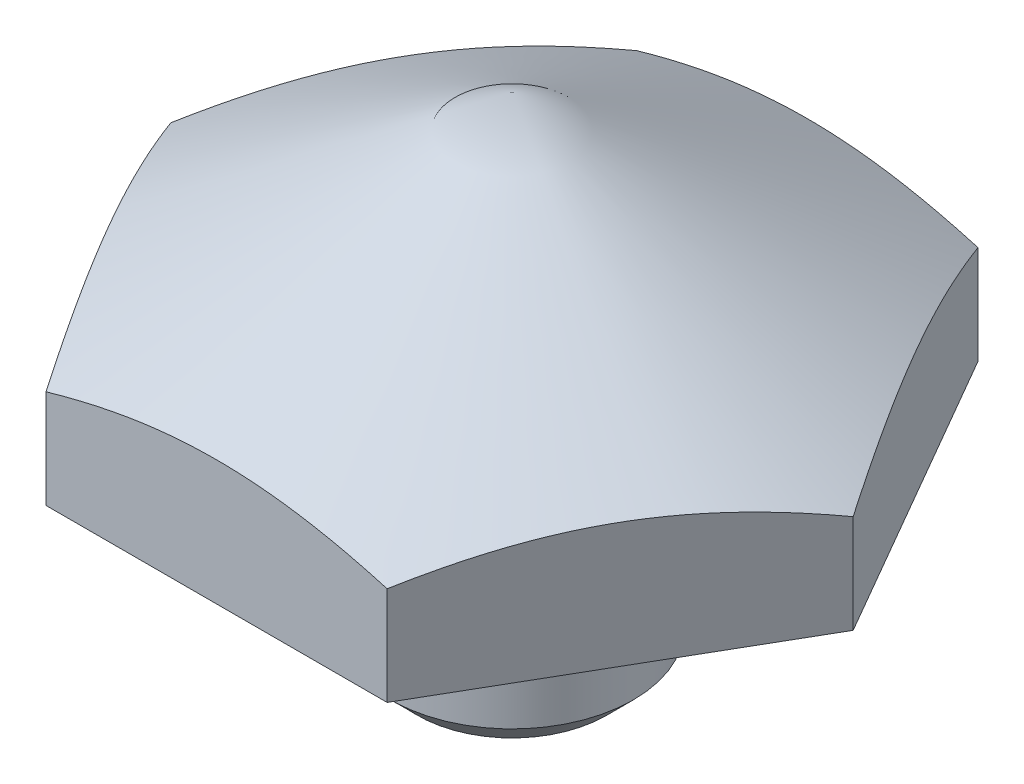
from build123d import *

# Parameters (mm, degrees)
CUT_EXTRUDE2_DEPTH = 15.875


with BuildPart() as part:
    # Sketch3 → Revolve1 (revolve)
    with BuildSketch(Plane.XY):
        with BuildLine():
            Line((0, 15.875), (10.9985175, 9.525002961))
            Line((10.9985175, 9.525002961), (10.9985175, 6.35))
            Line((10.9985175, 6.35), (3.429, 6.35))
            ThreePointArc((3.429, 6.35), (3.159592316, 6.238407684), (3.048, 5.969))
            Line((3.048, 5.969), (3.048, 4.3688))
            Line((3.048, 4.3688), (3.9116, 3.5052))
            Line((3.9116, 3.5052), (3.9116, 0.8636))
            Line((3.9116, 0.8636), (3.048, 0))
            Line((3.048, 0), (0, 0))
            Line((0, 0), (0, 15.875))
        make_face()
    revolve(axis=Axis((0, -1000, 0), (0, 1, 0)))

    # Sketch1 → Cut-Extrude2 (cut)
    with BuildSketch(Plane(origin=(0, 0, 0), x_dir=(1, 0, 0), z_dir=(0, 1, 0))):
        with BuildLine():
            ThreePointArc((-5.499261314, -9.525), (0, -10.998522628), (5.499261314, -9.525))
            Line((5.499261314, -9.525), (-5.499261314, -9.525))
        make_face()
        with BuildLine():
            ThreePointArc((-10.998522628, 0), (-9.525, -5.499261314), (-5.499261314, -9.525))
            Line((-5.499261314, -9.525), (-10.998522628, 0))
        make_face()
        with BuildLine():
            ThreePointArc((5.499261314, -9.525), (9.525, -5.499261314), (10.998522628, 0))
            Line((10.998522628, 0), (5.499261314, -9.525))
        make_face()
        with BuildLine():
            Line((5.499261314, 9.525), (10.998522628, 0))
            ThreePointArc((10.998522628, 0), (9.525, 5.499261314), (5.499261314, 9.525))
        make_face()
        with BuildLine():
            Line((-5.499261314, 9.525), (5.499261314, 9.525))
            ThreePointArc((5.499261314, 9.525), (0, 10.998522628), (-5.499261314, 9.525))
        make_face()
        with BuildLine():
            Line((-10.998522628, 0), (-5.499261314, 9.525))
            ThreePointArc((-5.499261314, 9.525), (-9.525, 5.499261314), (-10.998522628, 0))
        make_face()
    extrude(amount=CUT_EXTRUDE2_DEPTH, mode=Mode.SUBTRACT)


solid = part.part
